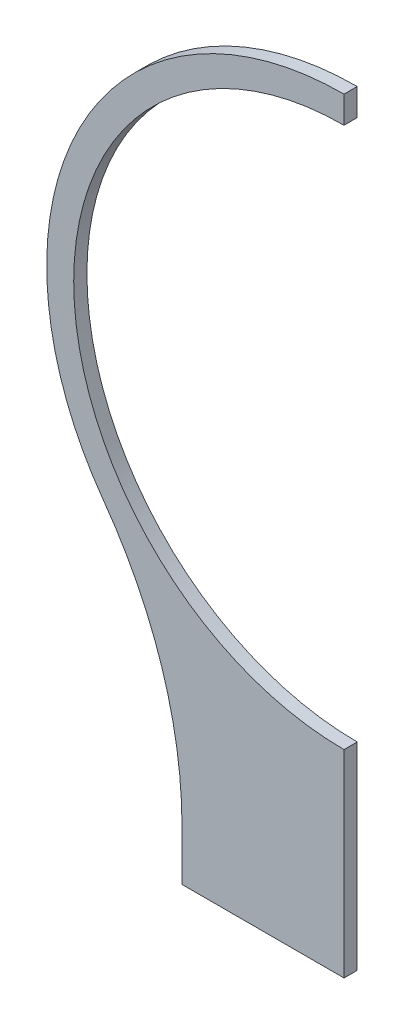
from build123d import *

# Parameters (mm, degrees)
BOSS_EXTRUDE3_DEPTH = 6.35


with BuildPart() as part:
    # Sketch1 → Boss-Extrude3 (new body)
    with BuildSketch(Plane.XY):
        with BuildLine():
            Line((0, 130.023), (0, 143.0035))
            ThreePointArc((0, 143.0035), (-127.347637401, 65.058283566), (-115.871551473, -83.808022119))
            ThreePointArc((-115.871551473, -83.808022119), (-87.648494018, -139.418965385), (-77.925699061, -201.019170265))
            Line((-77.925699061, -201.019170265), (-77.925699061, -225.171))
            Line((-77.925699061, -225.171), (0, -225.171))
            Line((0, -225.171), (0, -130.023))
            ThreePointArc((0, -130.023), (-130.023, 0), (0, 130.023))
        make_face()
    extrude(amount=BOSS_EXTRUDE3_DEPTH)


solid = part.part
